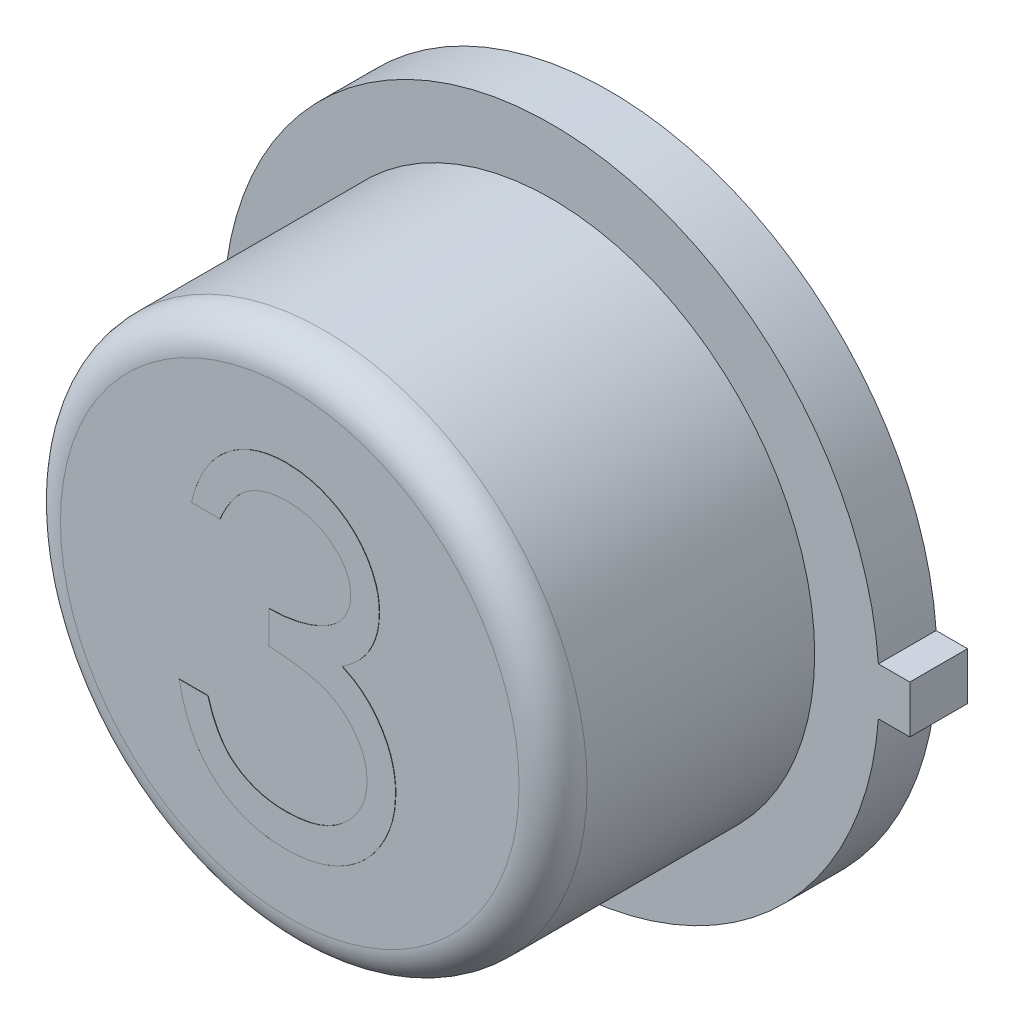
from build123d import *

# Parameters (mm, degrees)
BOSS_EXTRUDE1_DEPTH = 0.4318
SKETCH2_R           = 1.9685
BOSS_EXTRUDE2_DEPTH = 1.9558
SKETCH3_R           = 1.757566481
BOSS_EXTRUDE3_DEPTH = 0.00254
FILLET1_R           = 0.254
BOSS_EXTRUDE6_DEPTH = 0.00254


with BuildPart() as part:
    # Sketch1 → Boss-Extrude1 (new body)
    with BuildSketch(Plane.XY):
        with BuildLine():
            Line((2.6797, 0.1778), (2.4511, 0.1778))
            Line((2.4511, 0.1778), (2.44464279, 0.1778))
            ThreePointArc((2.44464279, 0.1778), (-2.4511, 0), (2.44464279, -0.1778))
            Line((2.44464279, -0.1778), (2.4511, -0.1778))
            Line((2.4511, -0.1778), (2.6797, -0.1778))
            Line((2.6797, -0.1778), (2.6797, 0.1778))
        make_face()
    extrude(amount=BOSS_EXTRUDE1_DEPTH)

    # Sketch2 → Boss-Extrude2 (add)
    with BuildSketch(Plane.XY.offset(0.4318)):
        Circle(SKETCH2_R)
    extrude(amount=BOSS_EXTRUDE2_DEPTH)

    # Sketch3 → Boss-Extrude3 (add)
    with BuildSketch(Plane(origin=(0, 0, 0), x_dir=(-1, 0, 0), z_dir=(0, 0, -1))):
        Circle(SKETCH3_R)
    extrude(amount=BOSS_EXTRUDE3_DEPTH)

    # Fillet1
    fillet1_edges = [part.edges().sort_by_distance(p)[0] for p in [
        (-1.9685, 0, 2.3876),
    ]]
    fillet(fillet1_edges, radius=FILLET1_R)

    # Sketch4 → Boss-Extrude6 (add)
    with BuildSketch(Plane.XY.offset(2.3876)):
        with BuildLine():
            Line((-0.518990385, 0.613589562), (-0.732692308, 0.613589562))
            add(Edge.make_bspline(
                [(-0.732692308, 0.613589562), (-0.726902774, 0.637560234), (-0.715584709, 0.684420938), (-0.691977968, 0.751373021), (-0.666260974, 0.814730274), (-0.635380173, 0.873306352), (-0.601696538, 0.928278463), (-0.563104829, 0.978399778), (-0.521385518, 1.024945028), (-0.475240329, 1.066251713), (-0.426847436, 1.103656203), (-0.375524954, 1.135547983), (-0.32230545, 1.162982809), (-0.266820193, 1.185584431), (-0.208903994, 1.202610725), (-0.149080447, 1.214963837), (-0.08719278, 1.222986006), (-0.045182366, 1.223768936), (-0.023850661, 1.224166485)],
                knots=[0, 0, 0, 0, 7.3931e-05, 0.000144529, 0.000212742, 0.000278882, 0.000342945, 0.000405913, 0.000468387, 0.000530188, 0.000591439, 0.00065166, 0.000711181, 0.000770884, 0.000831103, 0.000892006, 0.000954012, 0.001017976, 0.001017976, 0.001017976, 0.001017976], degree=3))
            add(Edge.make_bspline(
                [(-0.023850661, 1.224166485), (0.007229919, 1.223228116), (0.068713121, 1.221371846), (0.159039408, 1.204421132), (0.246143369, 1.177597961), (0.329071589, 1.140536372), (0.406100559, 1.094825003), (0.474637143, 1.040420424), (0.533752362, 0.978372327), (0.583346572, 0.909838208), (0.622177956, 0.836594013), (0.650811721, 0.761210335), (0.668243614, 0.683865993), (0.670502779, 0.63164363), (0.671634615, 0.605480338)],
                knots=[0, 0, 0, 0, 9.3165e-05, 0.000184299, 0.000274676, 0.00036607, 0.000456139, 0.000542705, 0.000627729, 0.00071246, 0.000795685, 0.000875689, 0.000953816, 0.001032256, 0.001032256, 0.001032256, 0.001032256], degree=3))
            add(Edge.make_bspline(
                [(0.671634615, 0.605480338), (0.670842958, 0.5803025), (0.669293807, 0.53103338), (0.656139982, 0.459105005), (0.634003704, 0.39131313), (0.603340169, 0.327372375), (0.563647078, 0.267688154), (0.515564404, 0.212126182), (0.458752772, 0.160440022), (0.415700494, 0.130831238), (0.393535907, 0.115587759)],
                knots=[0, 0, 0, 0, 7.549e-05, 0.000147723, 0.00021847, 0.000288876, 0.000359789, 0.000432846, 0.000508829, 0.000589457, 0.000589457, 0.000589457, 0.000589457], degree=3))
            add(Edge.make_bspline(
                [(0.393535907, 0.115587759), (0.418866798, 0.103356182), (0.469054617, 0.079121889), (0.537464888, 0.031595026), (0.599566443, -0.023280096), (0.634199152, -0.06610358), (0.65160006, -0.087619873)],
                knots=[0, 0, 0, 0, 8.4271e-05, 0.000166965, 0.000249046, 0.000331932, 0.000331932, 0.000331932, 0.000331932], degree=3))
            add(Edge.make_bspline(
                [(0.65160006, -0.087619873), (0.663058188, -0.103307379), (0.685786808, -0.134425497), (0.713841698, -0.18445653), (0.739293256, -0.235042096), (0.759125816, -0.287538049), (0.774484108, -0.341335939), (0.785462372, -0.396528141), (0.792282368, -0.453159724), (0.793259056, -0.491472322), (0.79375, -0.5107306)],
                knots=[0, 0, 0, 0, 5.8227e-05, 0.0001155, 0.00017182, 0.000227986, 0.00028355, 0.000339493, 0.000396649, 0.000454416, 0.000454416, 0.000454416, 0.000454416], degree=3))
            add(Edge.make_bspline(
                [(0.79375, -0.5107306), (0.79252909, -0.544074714), (0.790093015, -0.610606024), (0.768318815, -0.708900432), (0.734564092, -0.804984212), (0.686628212, -0.896883343), (0.628207639, -0.982867138), (0.558704174, -1.059799413), (0.478907529, -1.125929178), (0.389912971, -1.181181136), (0.29349471, -1.225348508), (0.190369174, -1.256003661), (0.082022262, -1.275969422), (0.007722297, -1.278110417), (-0.030051833, -1.279198899)],
                knots=[0, 0, 0, 0, 9.9919e-05, 0.000199368, 0.000300604, 0.000404715, 0.000509373, 0.0006117, 0.000714673, 0.000819238, 0.000925117, 0.001031803, 0.001141284, 0.001254506, 0.001254506, 0.001254506, 0.001254506], degree=3))
            add(Edge.make_bspline(
                [(-0.030051833, -1.279198899), (-0.055510321, -1.278608204), (-0.105604137, -1.277445913), (-0.179248374, -1.269500293), (-0.24954403, -1.254988272), (-0.316586149, -1.235459773), (-0.38043429, -1.210700392), (-0.440893619, -1.179867492), (-0.4983361, -1.14359663), (-0.552219672, -1.101459672), (-0.602537912, -1.054323617), (-0.647953605, -1.001351684), (-0.689223928, -0.943523093), (-0.72524383, -0.880166156), (-0.757653971, -0.812099651), (-0.784311015, -0.738452012), (-0.807773518, -0.659881633), (-0.818682, -0.605128027), (-0.824278846, -0.577035438)],
                knots=[0, 0, 0, 0, 7.6376e-05, 0.000150282, 0.000221848, 0.000291435, 0.000359554, 0.000426967, 0.000494723, 0.000563043, 0.000631881, 0.000701213, 0.000772025, 0.000844681, 0.000919578, 0.000997909, 0.001079421, 0.00116531, 0.00116531, 0.00116531, 0.00116531], degree=3))
            Line((-0.824278846, -0.577035438), (-0.610576923, -0.577035438))
            add(Edge.make_bspline(
                [(-0.610576923, -0.577035438), (-0.605009362, -0.595370391), (-0.594179973, -0.631033469), (-0.575746174, -0.68235982), (-0.554744724, -0.729411995), (-0.532214998, -0.772535155), (-0.508553234, -0.812153986), (-0.482077186, -0.847220865), (-0.454747822, -0.879276029), (-0.434147047, -0.897335845), (-0.424064754, -0.90617456)],
                knots=[0, 0, 0, 0, 5.7482e-05, 0.000111807, 0.000163485, 0.000211918, 0.000257731, 0.000301712, 0.000343624, 0.000383798, 0.000383798, 0.000383798, 0.000383798], degree=3))
            add(Edge.make_bspline(
                [(-0.424064754, -0.90617456), (-0.410732083, -0.916453623), (-0.384107896, -0.93698002), (-0.340722725, -0.963174878), (-0.29509465, -0.98587229), (-0.246235024, -1.003210304), (-0.195198189, -1.01789082), (-0.141159214, -1.027497816), (-0.084594853, -1.034089232), (-0.0459725, -1.034670891), (-0.026235727, -1.03496813)],
                knots=[0, 0, 0, 0, 5.0469e-05, 0.000100782, 0.000151769, 0.000203078, 0.000256087, 0.000310912, 0.00036754, 0.000426721, 0.000426721, 0.000426721, 0.000426721], degree=3))
            add(Edge.make_bspline(
                [(-0.026235727, -1.03496813), (-0.003951648, -1.034549094), (0.039622946, -1.033729707), (0.103205627, -1.02619427), (0.163694444, -1.015219828), (0.22041781, -0.998270103), (0.274118744, -0.97732813), (0.324044474, -0.951033412), (0.370850396, -0.920182806), (0.413937009, -0.885117772), (0.452680292, -0.846731005), (0.486793068, -0.80658104), (0.515793061, -0.764837163), (0.539186174, -0.72126837), (0.557658245, -0.676055081), (0.570233422, -0.629070413), (0.578977042, -0.58069888), (0.579689112, -0.547817921), (0.580048077, -0.531242168)],
                knots=[0, 0, 0, 0, 6.6824e-05, 0.000130669, 0.000191854, 0.000251023, 0.000307979, 0.000364521, 0.000419955, 0.000475904, 0.000530885, 0.00058335, 0.000633762, 0.000683063, 0.000731428, 0.000779917, 0.000828773, 0.00087844, 0.00087844, 0.00087844, 0.00087844], degree=3))
            add(Edge.make_bspline(
                [(0.580048077, -0.531242168), (0.579006925, -0.509054811), (0.576929803, -0.464790498), (0.561071644, -0.399668362), (0.534987524, -0.336923505), (0.498471048, -0.277626441), (0.454019418, -0.222669979), (0.402064008, -0.173635631), (0.342173374, -0.13317473), (0.287050928, -0.105219769), (0.238224991, -0.086144545), (0.196440595, -0.073438899), (0.149661549, -0.062679966), (0.098453551, -0.052670367), (0.042430756, -0.044151378), (-0.018345846, -0.037047214), (-0.083888569, -0.031362802), (-0.129262381, -0.028824325), (-0.152644231, -0.027516207)],
                knots=[0, 0, 0, 0, 6.6512e-05, 0.000132693, 0.000199842, 0.000269625, 0.000340845, 0.00041138, 0.000483093, 0.000556905, 0.000596324, 0.000640233, 0.000687786, 0.000740268, 0.000796736, 0.000857737, 0.000923814, 0.000994066, 0.000994066, 0.000994066, 0.000994066], degree=3))
            Line((-0.152644231, -0.027516207), (-0.152644231, 0.216714562))
            add(Edge.make_bspline(
                [(-0.152644231, 0.216714562), (-0.123183973, 0.217214491), (-0.065478566, 0.218193729), (0.018813809, 0.230037394), (0.099417973, 0.246420821), (0.174547596, 0.271515925), (0.243024667, 0.300662627), (0.302433182, 0.334579934), (0.35194083, 0.372281754), (0.391307024, 0.414350012), (0.420922445, 0.459467928), (0.442576034, 0.50649194), (0.45536697, 0.555834202), (0.45707444, 0.589508253), (0.457932692, 0.606434364)],
                knots=[0, 0, 0, 0, 8.8311e-05, 0.000172979, 0.000254936, 0.000334734, 0.000410148, 0.000477894, 0.000539436, 0.000596138, 0.000649853, 0.000700661, 0.000750872, 0.000801617, 0.000801617, 0.000801617, 0.000801617], degree=3))
            add(Edge.make_bspline(
                [(0.457932692, 0.606434364), (0.457650745, 0.618869758), (0.457089824, 0.643609386), (0.450015962, 0.679753406), (0.439386034, 0.714792442), (0.424772146, 0.748577488), (0.405211743, 0.780874228), (0.381803385, 0.81195801), (0.353930445, 0.841651367), (0.321990775, 0.869328513), (0.287692743, 0.895705441), (0.250103164, 0.918098469), (0.210355424, 0.937247163), (0.168405518, 0.953037913), (0.124117309, 0.964916465), (0.077698883, 0.973445314), (0.029061727, 0.978777718), (-0.004120469, 0.979545444), (-0.020988582, 0.979935716)],
                knots=[0, 0, 0, 0, 3.7256e-05, 7.4119e-05, 0.000110031, 0.000146987, 0.000184209, 0.000223038, 0.000263537, 0.000306122, 0.000349721, 0.000393161, 0.000437111, 0.000481942, 0.000527419, 0.000574479, 0.000623416, 0.000674016, 0.000674016, 0.000674016, 0.000674016], degree=3))
            add(Edge.make_bspline(
                [(-0.020988582, 0.979935716), (-0.048101949, 0.978989093), (-0.101060661, 0.977140118), (-0.177406881, 0.960945568), (-0.248381285, 0.935106907), (-0.302632056, 0.904264264), (-0.342693236, 0.873817987), (-0.371320582, 0.847228006), (-0.399433286, 0.817678174), (-0.425181863, 0.783348458), (-0.451221836, 0.746563731), (-0.474928582, 0.705454048), (-0.497965266, 0.661091772), (-0.511846286, 0.629730278), (-0.518990385, 0.613589562)],
                knots=[0, 0, 0, 0, 8.1262e-05, 0.000158723, 0.000232978, 0.000307113, 0.000344894, 0.00038372, 0.000424218, 0.000467059, 0.000512313, 0.000559354, 0.000609276, 0.000662216, 0.000662216, 0.000662216, 0.000662216], degree=3))
        make_face()
    extrude(amount=BOSS_EXTRUDE6_DEPTH)


solid = part.part
